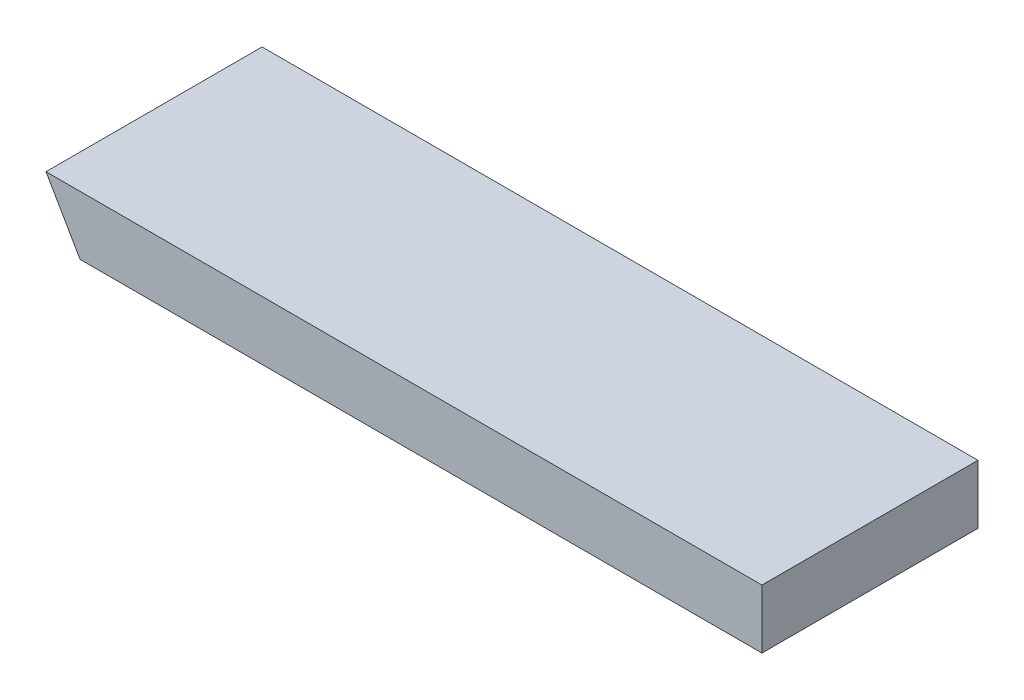
from build123d import *

# Parameters (mm, degrees)
SKETCH1_W           = 508
SKETCH1_H           = 139.7
BOSS_EXTRUDE1_DEPTH = 38.1
CUT_EXTRUDE1_DEPTH  = 140.7


with BuildPart() as part:
    # Sketch1 → Boss-Extrude1 (new body)
    with BuildSketch(Plane(origin=(0, 0, 0), x_dir=(1, 0, 0), z_dir=(0, 1, 0))):
        with Locations((254, 69.85)):
            Rectangle(SKETCH1_W, SKETCH1_H)
    extrude(amount=BOSS_EXTRUDE1_DEPTH)

    # Sketch2 → Cut-Extrude1 (cut, through all)
    with BuildSketch(Plane.XY):
        Polygon((45.087928127, 38.1), (67.084973383, 0), (0, 0), (0, 38.1), align=None)
    extrude(amount=-CUT_EXTRUDE1_DEPTH, mode=Mode.SUBTRACT)


solid = part.part
